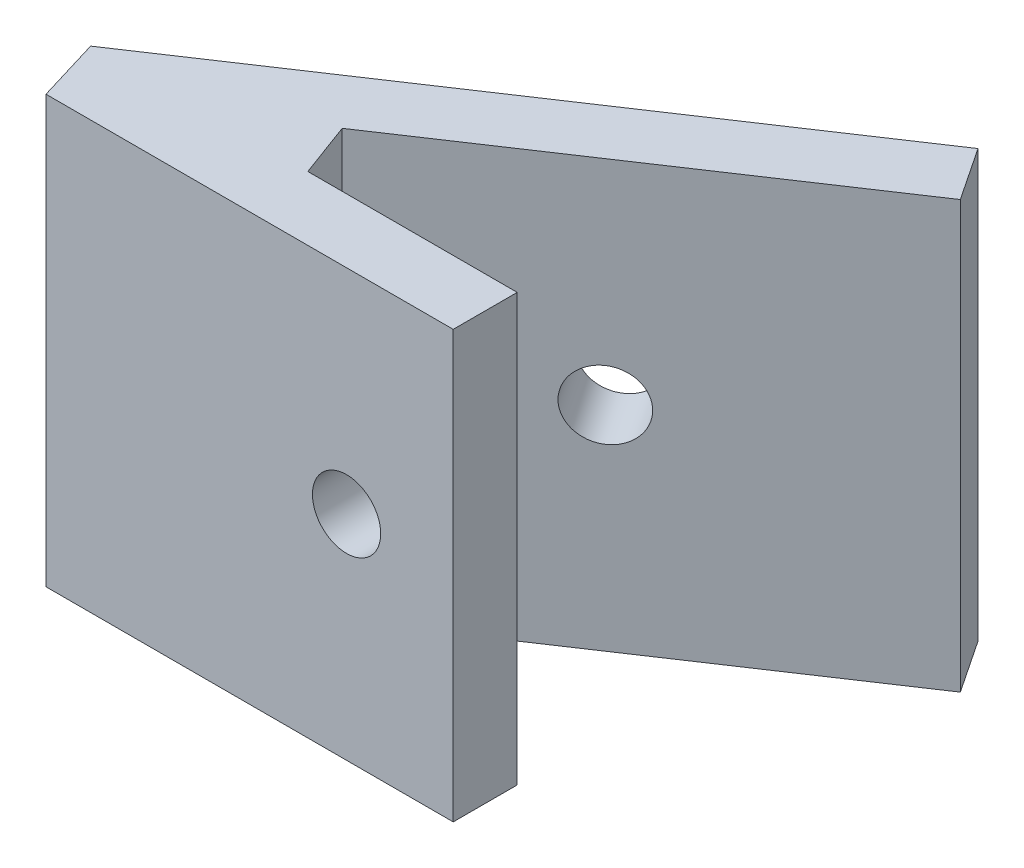
from build123d import *

# Parameters (mm, degrees)
EXTRUDE_1_DEPTH     = 20
SKETCH_4_R          = 1.6
CUT_EXTRUDE_1_DEPTH = 4
CUT_EXTRUDE_2_REACH = 19.261
SKETCH_5_R          = 1.6


with BuildPart() as part:
    # 草图1 → 凸台-拉伸1 (new body)
    with BuildSketch(Plane(origin=(0, 0, 0), x_dir=(1, 0, 0), z_dir=(0, 1, 0))):
        Polygon((3.90131241, 80.330794947), (22.992985496, 80.330794947), (22.992985496, 83.330794947), (13.176134515, 83.330794947), (12.229840324, 85.890335427), (29.611004769, 97.487035171), (27.954494327, 99.971800834), (2.992985496, 83.330794947), align=None)
    extrude(amount=EXTRUDE_1_DEPTH)

    # 草图4 → 切除-拉伸1 (cut, through all)
    with BuildSketch(Plane(origin=(0, 0, -83.330794947), x_dir=(-1, 0, 0), z_dir=(0, 0, -1))):
        with Locations((-17.992985496, 10)):
            Circle(SKETCH_4_R)
    extrude(amount=-CUT_EXTRUDE_1_DEPTH, mode=Mode.SUBTRACT)

    # 草图5 → 切除-拉伸2 (cut, up to next)
    with BuildSketch(Plane(origin=(-37.539448284, 0, -56.309172427), x_dir=(-0.832050294, 0, 0.554700196), z_dir=(-0.554700196, 0, -0.832050294)), mode=Mode.PRIVATE) as cut_extrude_2_sk1:
        with Locations((-66.713922772, 10)):
            Circle(SKETCH_5_R)
    cut_extrude_2_tool1 = extrude(cut_extrude_2_sk1.sketch, amount=-CUT_EXTRUDE_2_REACH, mode=Mode.PRIVATE) & part.part
    add(cut_extrude_2_tool1.solids().sort_by_distance((17.969891, 10, -93.315398))[0], mode=Mode.SUBTRACT)


solid = part.part
